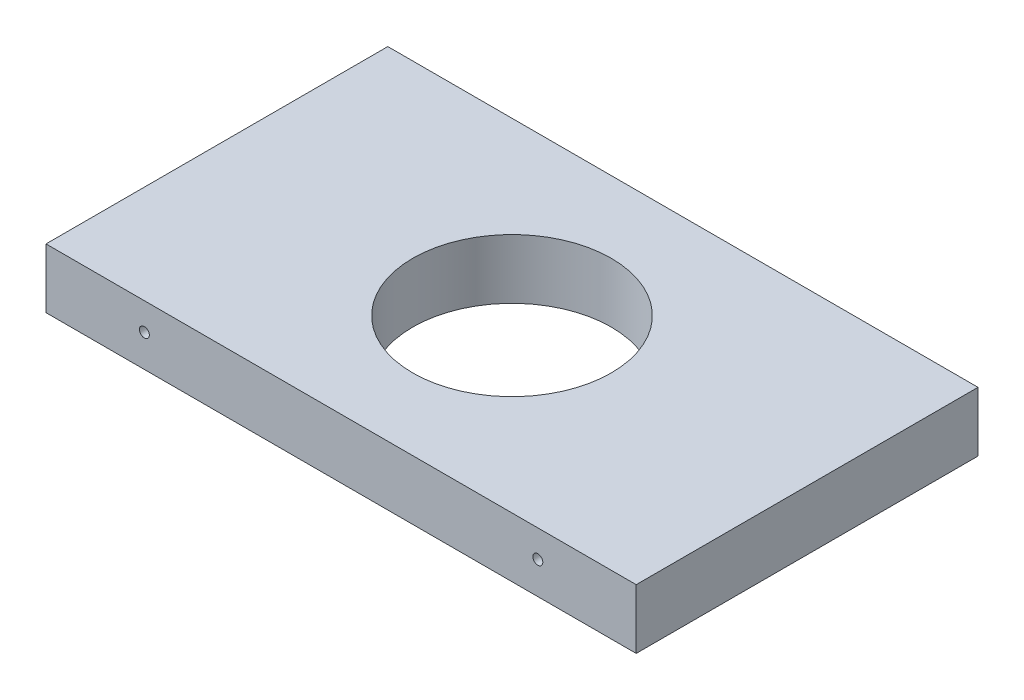
from build123d import *

# Parameters (mm, degrees)
SKETCH1_W           = 188.724999994
SKETCH1_H           = 19.05
BOSS_EXTRUDE1_DEPTH = 109.3
HOLE1_D             = 3.175
HOLE1_DEPTH         = 31.75
HOLE1_CSINK_D       = 10.16
HOLE1_CSINK_ANGLE   = 82
HOLE1_TIP           = 0.953866233
HOLE2_D             = 3.175
HOLE2_DEPTH         = 31.75
HOLE2_CSINK_D       = 10.16
HOLE2_CSINK_ANGLE   = 82
HOLE2_TIP           = 0.953866233
HOLE3_D             = 3.175
HOLE3_DEPTH         = 31.75
HOLE3_CSINK_D       = 10.16
HOLE3_CSINK_ANGLE   = 82
HOLE3_TIP           = 0.953866233
HOLE4_D             = 63.5
HOLE4_DEPTH         = 19.05


with BuildPart() as part:
    # Sketch1 → Boss-Extrude1 (new body)
    with BuildSketch(Plane.XY):
        with Locations((-227.891965966, -292.321060846)):
            Rectangle(SKETCH1_W, SKETCH1_H)
    extrude(amount=BOSS_EXTRUDE1_DEPTH)

    # Hole1
    with Locations(Plane(origin=(-124.004465969, 10.424290059, -12.7), x_dir=(1, 0, 0), z_dir=(0, 0, -1))):
        with Locations((113.649999994, 128.807623392), (113.649999994, 23.940956725), (-94.599999994, 161.374290059), (94.599999994, 161.374290059), (0, 161.374290059), (0, 193.124290059), (0, 440.553783621), (0, 301.970350905), (40.979166666, 301.970350905), (166.795833328, 301.970350905), (207.774999994, 440.553783621), (207.774999994, 333.02141023), (207.774999994, 225.48903684), (207.774999994, 137.424290059), (207.774999994, 10.424290059), (-207.774999994, 10.424290059), (-207.774999994, 137.424290059), (-207.774999994, 225.48903684), (-207.774999994, 333.02141023), (-207.774999994, 440.553783621), (-166.795833328, 301.970350905), (-40.979166666, 301.970350905), (-113.649999994, 23.940956725), (-113.649999994, 128.807623392)):
            CounterSinkHole(HOLE1_D / 2, HOLE1_CSINK_D / 2, depth=HOLE1_DEPTH, counter_sink_angle=HOLE1_CSINK_ANGLE)
            with Locations((0, 0, -(HOLE1_DEPTH + HOLE1_TIP / 2))):  # 118° drill point
                Cone(0, HOLE1_D / 2, HOLE1_TIP, mode=Mode.SUBTRACT)

    # Hole2
    with Locations(Plane(origin=(-124.004465969, 10.424290059, 122), x_dir=(-1, 0, 0), z_dir=(0, 0, 1))):
        with Locations((113.649999994, 128.807623392), (113.649999994, 23.940956725), (-94.599999994, 161.374290059), (94.599999994, 161.374290059), (0, 161.374290059), (0, 193.124290059), (0, 440.553783621), (0, 301.970350905), (40.979166666, 301.970350905), (166.795833328, 301.970350905), (207.774999994, 440.553783621), (207.774999994, 333.02141023), (207.774999994, 225.48903684), (207.774999994, 137.424290059), (207.774999994, 10.424290059), (-207.774999994, 10.424290059), (-207.774999994, 137.424290059), (-207.774999994, 225.48903684), (-207.774999994, 333.02141023), (-207.774999994, 440.553783621), (-166.795833328, 301.970350905), (-40.979166666, 301.970350905), (-113.649999994, 23.940956725), (-113.649999994, 128.807623392)):
            CounterSinkHole(HOLE2_D / 2, HOLE2_CSINK_D / 2, depth=HOLE2_DEPTH, counter_sink_angle=HOLE2_CSINK_ANGLE)
            with Locations((0, 0, -(HOLE2_DEPTH + HOLE2_TIP / 2))):  # 118° drill point
                Cone(0, HOLE2_D / 2, HOLE2_TIP, mode=Mode.SUBTRACT)

    # Hole3
    with Locations(Plane(origin=(-124.004465969, 10.424290059, 122), x_dir=(-1, 0, 0), z_dir=(0, 0, 1))):
        with Locations((-207.774999994, 333.02141023), (-207.774999994, 225.48903684), (-207.774999994, 137.424290059), (-172.166666661, 4.074290059), (-146.083333327, 4.074290059), (-94.599999994, 161.374290059), (0, 161.374290059), (94.599999994, 161.374290059), (146.083333327, 4.074290059), (172.166666661, 4.074290059), (207.774999994, 137.424290059), (207.774999994, 225.48903684), (207.774999994, 333.02141023), (166.795833328, 301.970350905), (40.979166666, 301.970350905), (-40.979166666, 301.970350905), (-166.795833328, 301.970350905), (0, 193.124290059), (0, 301.970350905), (0, 412.366411751), (-126.349999994, 106.824290059), (-126.349999994, 58.624290059), (126.349999994, 58.624290059), (126.349999994, 106.824290059)):
            CounterSinkHole(HOLE3_D / 2, HOLE3_CSINK_D / 2, depth=HOLE3_DEPTH, counter_sink_angle=HOLE3_CSINK_ANGLE)
            with Locations((0, 0, -(HOLE3_DEPTH + HOLE3_TIP / 2))):  # 118° drill point
                Cone(0, HOLE3_D / 2, HOLE3_TIP, mode=Mode.SUBTRACT)

    # Hole4
    with Locations(Plane(origin=(0, -282.796060846, 0), x_dir=(1, 0, 0), z_dir=(0, 1, 0))):
        with Locations((-227.891965966, -54.65)):
            Hole(HOLE4_D / 2, depth=HOLE4_DEPTH)


solid = part.part
